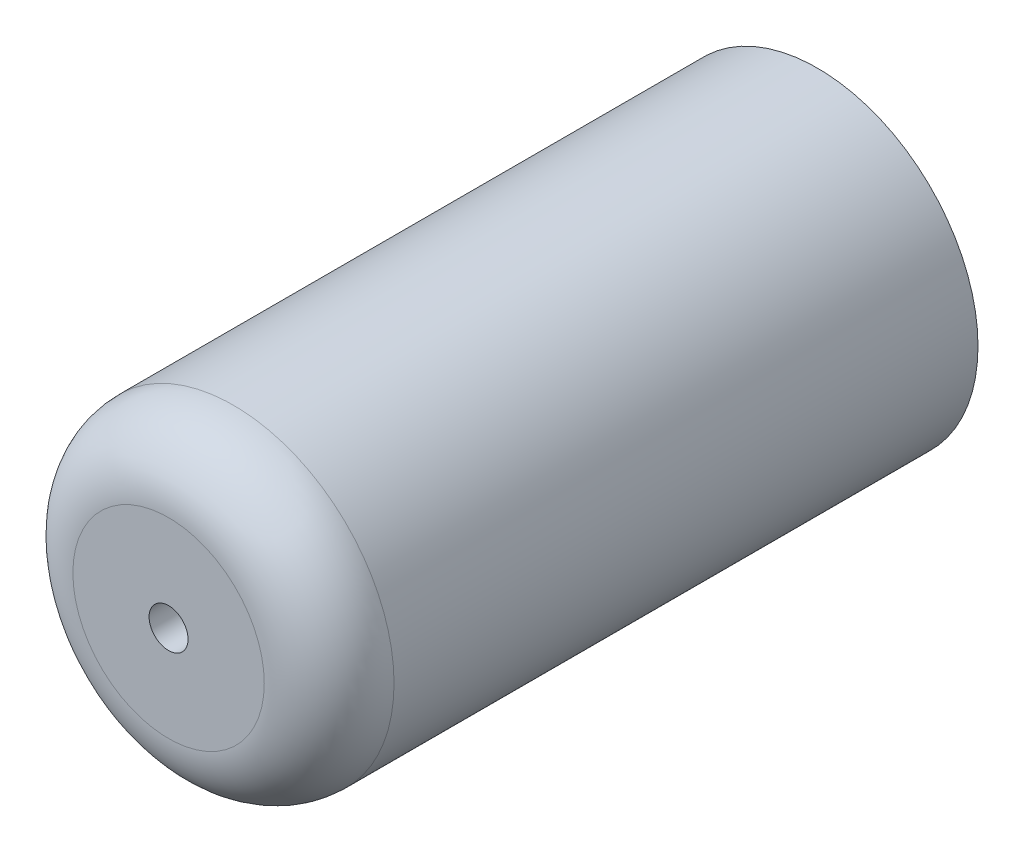
from build123d import *

# Parameters (mm, degrees)
ESQUISSE1_R             = 12.375
BOSS_EXTRU_1_DEPTH      = 50
CONG_2_R                = 5
ESQUISSE2_R             = 1.5
ENL_V_MAT_EXTRU_1_DEPTH = 51


with BuildPart() as part:
    # Esquisse1 → Boss.-Extru.1 (new body)
    with BuildSketch(Plane.XY):
        Circle(ESQUISSE1_R)
    extrude(amount=BOSS_EXTRU_1_DEPTH)

    # Congé2
    cong_2_edges = [part.edges().sort_by_distance(p)[0] for p in [
        (-12.375, 0, 50),
    ]]
    fillet(cong_2_edges, radius=CONG_2_R)

    # Esquisse2 → Enlèv. mat.-Extru.1 (cut, through all)
    with BuildSketch(Plane(origin=(0, 0, 0), x_dir=(-1, 0, 0), z_dir=(0, 0, -1))):
        Circle(ESQUISSE2_R)
    extrude(amount=-ENL_V_MAT_EXTRU_1_DEPTH, mode=Mode.SUBTRACT)


solid = part.part
